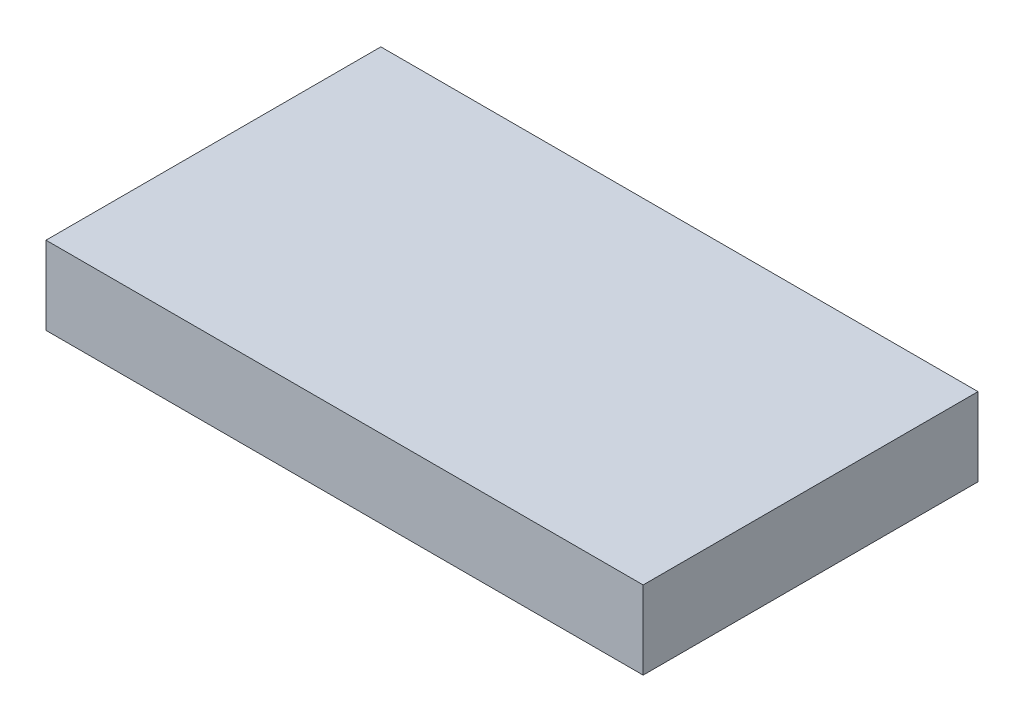
from build123d import *

# Parameters (mm, degrees)
SKETCH1_W           = 53.5
SKETCH1_H           = 30
BOSS_EXTRUDE1_DEPTH = 7


with BuildPart() as part:
    # Sketch1 → Boss-Extrude1 (new body)
    with BuildSketch(Plane(origin=(0, 0, 0), x_dir=(1, 0, 0), z_dir=(0, 1, 0))):
        with Locations((-26.75, -15)):
            Rectangle(SKETCH1_W, SKETCH1_H)
    extrude(amount=BOSS_EXTRUDE1_DEPTH)


solid = part.part
